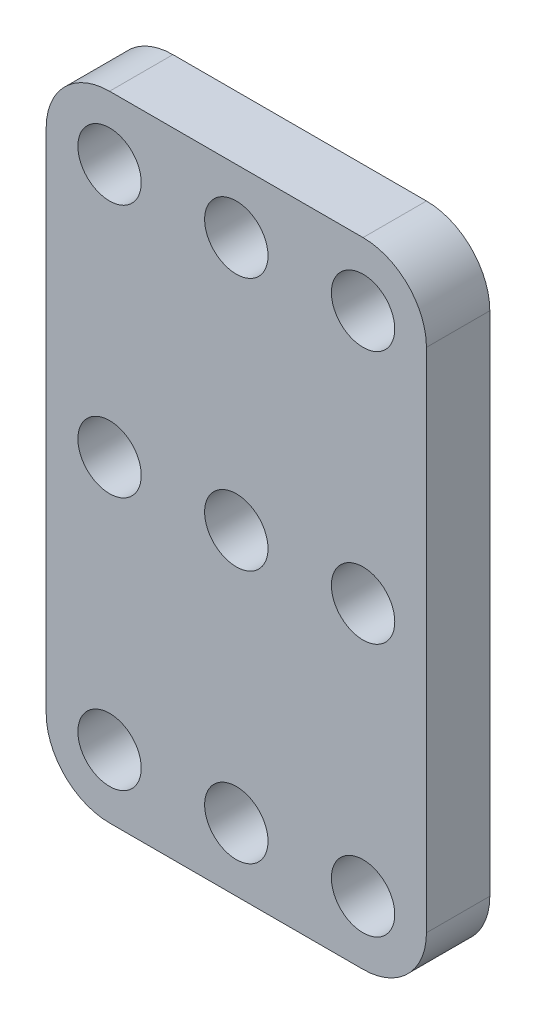
from build123d import *

# Parameters (mm, degrees)
IZIM1_W             = 30
IZIM1_H             = 50
IZIM1_R             = 2.5
BOSS_EXTRUDE1_DEPTH = 5
FILLET1_R           = 5


with BuildPart() as part:
    # Çizim1 → Boss-Extrude1 (new body)
    with BuildSketch(Plane.XY):
        with Locations((-49.096295608, -2.166722038)):
            Rectangle(IZIM1_W, IZIM1_H)
        with Locations((-59.096295608, 17.833277962)):
            Circle(IZIM1_R, mode=Mode.SUBTRACT)
        with Locations((-49.096295608, 17.833277962)):
            Circle(IZIM1_R, mode=Mode.SUBTRACT)
        with Locations((-39.096295608, 17.833277962)):
            Circle(IZIM1_R, mode=Mode.SUBTRACT)
        with Locations((-49.096295608, -2.166722038)):
            Circle(IZIM1_R, mode=Mode.SUBTRACT)
        with Locations((-39.096295608, -2.166722038)):
            Circle(IZIM1_R, mode=Mode.SUBTRACT)
        with Locations((-49.096295608, -22.166722038)):
            Circle(IZIM1_R, mode=Mode.SUBTRACT)
        with Locations((-39.096295608, -22.166722038)):
            Circle(IZIM1_R, mode=Mode.SUBTRACT)
        with Locations((-59.096295608, -2.166722038)):
            Circle(IZIM1_R, mode=Mode.SUBTRACT)
        with Locations((-59.096295608, -22.166722038)):
            Circle(IZIM1_R, mode=Mode.SUBTRACT)
    extrude(amount=BOSS_EXTRUDE1_DEPTH)

    # Fillet1
    fillet1_edges = [part.edges().sort_by_distance(p)[0] for p in [
        (-64.096295608, 22.833277962, 2.5),
        (-34.096295608, 22.833277962, 2.5),
        (-34.096295608, -27.166722038, 2.5),
        (-64.096295608, -27.166722038, 2.5),
    ]]
    fillet(fillet1_edges, radius=FILLET1_R)


solid = part.part
